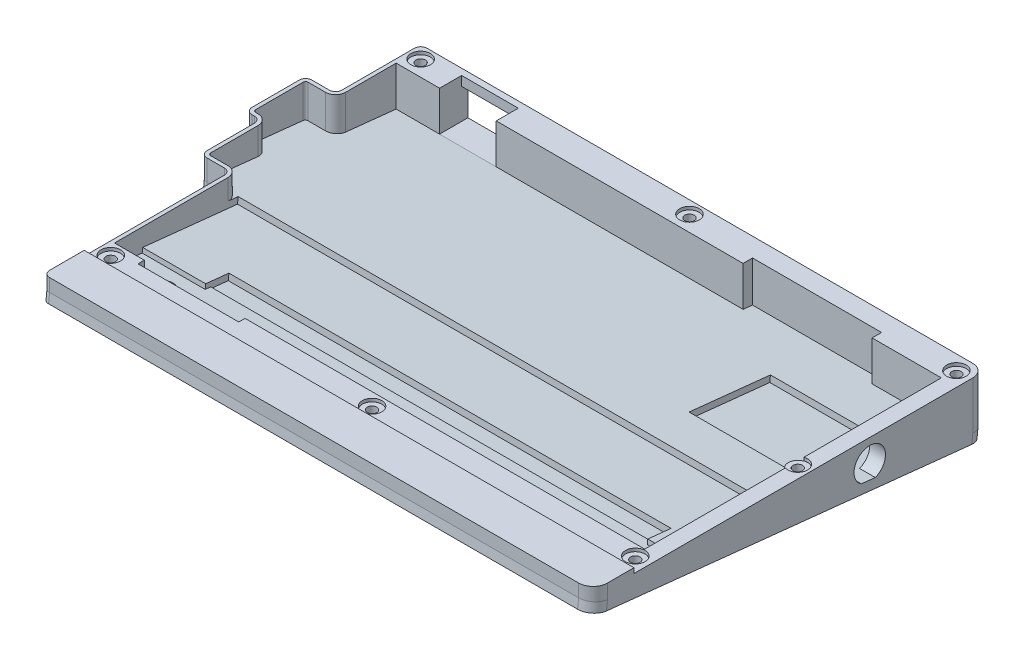
from build123d import *

# Parameters (mm, degrees)
SKETCH1_R                = 1.1
BOSS_EXTRUDE2_DEPTH      = 4.7
BOSS_EXTRUDE2_2_DEPTH    = 4.7
BODY_MOVE_COPY1_ANGLE    = 180
BOSS_EXTRUDE3_REACH      = 207.065
CUT_EXTRUDE1_DEPTH       = 171.122265517
CUT_EXTRUDE2_DEPTH       = 173.598879961
BOSS_EXTRUDE4_DEPTH      = 182.770947
BOSS_EXTRUDE10_DEPTH     = 11
CUT_EXTRUDE8_DEPTH       = 11
BOSS_EXTRUDE11_REACH     = 183.171
BOSS_EXTRUDE14_REACH     = 156.96
SKETCH47_R               = 3.1
CUT_EXTRUDE17_DEPTH      = 1.8
CUT_EXTRUDE18_DEPTH      = 0.8
CUT_EXTRUDE19_DEPTH      = 10
SKETCH50_W               = 39
SKETCH50_H               = 26
CUT_EXTRUDE20_DEPTH      = 10
SKETCH51_W               = 168.69
SKETCH51_H               = 3.9
BOSS_EXTRUDE15_DEPTH     = 13.5
SKETCH52_W               = 168.69
SKETCH52_H               = 3.9
CUT_EXTRUDE21_DEPTH      = 13.5
BOSS_EXTRUDE16_DEPTH     = 174.69
SKETCH54_W               = 2
SKETCH54_H               = 1.96610301
SKETCH54_H_2             = 3.9
BOSS_EXTRUDE17_DEPTH     = 2
SKETCH55_W               = 4
SKETCH55_H               = 3.9
SKETCH55_H_2             = 2.74608012
BOSS_EXTRUDE18_DEPTH     = 4
CUT_EXTRUDE22_DEPTH      = 13.5
CUT_EXTRUDE22_DEPTH_BACK = 13.5
CUT_EXTRUDE23_DEPTH      = 13.5
CUT_EXTRUDE23_DEPTH_BACK = 13.5
CUT_EXTRUDE24_START      = -2.9
SKETCH58_R               = 1.1
CUT_EXTRUDE24_DEPTH      = 2.9
SKETCH59_R               = 3.1
CUT_EXTRUDE25_DEPTH      = 1
SKETCH60_R               = 3.1
CUT_EXTRUDE26_DEPTH      = 1
CUT_EXTRUDE27_DEPTH      = 13.5
SKETCH62_W               = 39
SKETCH62_H               = 26
SKETCH62_W_2             = 168.490946585
SKETCH62_H_2             = 24.16499069
BOSS_EXTRUDE20_DEPTH     = 2
SKETCH63_W               = 18
SKETCH63_H               = 9
CUT_EXTRUDE28_DEPTH      = 12.646908
CUT_EXTRUDE29_DEPTH      = 14
SKETCH67_R               = 1.5
CUT_EXTRUDE30_DEPTH      = 4
SKETCH68_W               = 168.490946585
SKETCH68_H               = 15.350532898
CUT_EXTRUDE31_DEPTH      = 2
SKETCH69_W               = 168.490946585
SKETCH69_H               = 24.16499069
CUT_EXTRUDE32_DEPTH      = 20
SKETCH70_W               = 32
SKETCH70_H               = 2.011016559
CUT_EXTRUDE33_DEPTH      = 20
SKETCH72_W               = 168.490946585
SKETCH72_H               = 1.989043791
BOSS_EXTRUDE21_DEPTH     = 7.5
SKETCH74_W               = 168.490946585
SKETCH74_H               = 0.5
BOSS_EXTRUDE22_DEPTH     = 11
SKETCH76_W               = 32
SKETCH76_H               = 0.5
BOSS_EXTRUDE23_DEPTH     = 2.011016559
SKETCH81_W               = 8
SKETCH81_H               = 1.989043791
SKETCH81_W_2             = 20
BOSS_EXTRUDE24_DEPTH     = 7.45
SKETCH82_R               = 2.5
CUT_EXTRUDE34_DEPTH      = 0.5
BOSS_EXTRUDE25_DEPTH     = 1
BOSS_EXTRUDE27_DEPTH     = 1
SKETCH90_W               = 5.5
SKETCH90_H               = 5.5
CUT_EXTRUDE35_DEPTH      = 2
BOSS_EXTRUDE28_START     = -5
BOSS_EXTRUDE28_DEPTH     = 5
BOSS_EXTRUDE29_DEPTH     = 1.6
CUT_EXTRUDE36_DEPTH      = 1.6
BOSS_EXTRUDE30_REACH     = 179.446
SKETCH94_R               = 3
SKETCH94_R_2             = 1.5
SKETCH95_R               = 1.5
CUT_EXTRUDE37_DEPTH      = 4
SKETCH96_R               = 1.5
CUT_EXTRUDE38_DEPTH      = 1.3
SKETCH97_W               = 18
SKETCH97_H               = 2
BOSS_EXTRUDE31_DEPTH     = 3
BOSS_EXTRUDE32_DEPTH     = 2


with BuildPart() as part:
    # Sketch1 → Boss-Extrude2 (new body)
    with BuildSketch(Plane(origin=(0, 0, 0), x_dir=(1, 0, 0), z_dir=(0, 1, 0))):
        with BuildLine():
            Line((138.419647052, 31.751786673), (125.419647052, 31.751786673))
            Line((125.419647052, 31.751786673), (125.419647052, 22.751786673))
            Line((125.419647052, 22.751786673), (139.220593636, 22.751786673))
            Line((139.220593636, 22.751786673), (139.220593636, 6.701786673))
            ThreePointArc((139.220593636, 6.701786673), (140.157574688, 4.43971431), (142.419647052, 3.502733258))
            Line((142.419647052, 3.502733258), (147.949647052, 3.502733258))
            ThreePointArc((147.949647052, 3.502733258), (148.516001813, 3.268141435), (148.750593636, 2.701786673))
            Line((148.750593636, 2.701786673), (148.750593636, -12.348213327))
            ThreePointArc((148.750593636, -12.348213327), (148.516001813, -12.914568088), (147.949647052, -13.149159912))
            Line((147.949647052, -13.149159912), (147.189647052, -13.149159912))
            ThreePointArc((147.189647052, -13.149159912), (144.927574688, -14.086140963), (143.990593636, -16.348213327))
            Line((143.990593636, -16.348213327), (143.990593636, -31.398213327))
            ThreePointArc((143.990593636, -31.398213327), (143.756001813, -31.964568088), (143.189647052, -32.199159912))
            Line((143.189647052, -32.199159912), (137.669647052, -32.199159912))
            ThreePointArc((137.669647052, -32.199159912), (135.407574688, -33.136140963), (134.470593636, -35.398213327))
            Line((134.470593636, -35.398213327), (134.470593636, -71.498213327))
            Line((134.470593636, -71.498213327), (124.979647052, -71.498213327))
            Line((124.979647052, -71.498213327), (124.979647052, -73.498213327))
            Line((124.979647052, -73.498213327), (92.979647052, -73.498213327))
            Line((92.979647052, -73.498213327), (92.979647052, -71.498213327))
            Line((92.979647052, -71.498213327), (-34.020352948, -71.498213327))
            Line((-34.020352948, -71.498213327), (-34.020352948, -25.600264134))
            ThreePointArc((-34.020352948, -25.600264134), (-33.020352948, -23.868213327), (-34.020352948, -22.136162519))
            Line((-34.020352948, -22.136162519), (-34.020352948, -13.498213327))
            Line((-34.020352948, -13.498213327), (-39.020352948, -13.498213327))
            Line((-39.020352948, -13.498213327), (-39.020352948, -75.498213327))
            ThreePointArc((-39.020352948, -75.498213327), (-37.848780073, -78.326640452), (-35.020352948, -79.498213327))
            Line((-35.020352948, -79.498213327), (133.669647052, -79.498213327))
            ThreePointArc((133.669647052, -79.498213327), (135.083860614, -78.912426889), (135.669647052, -77.498213327))
            Line((135.669647052, -77.498213327), (135.669647052, -35.398213327))
            ThreePointArc((135.669647052, -35.398213327), (136.255433489, -33.983999764), (137.669647052, -33.398213327))
            Line((137.669647052, -33.398213327), (143.189647052, -33.398213327))
            ThreePointArc((143.189647052, -33.398213327), (144.603860614, -32.812426889), (145.189647052, -31.398213327))
            Line((145.189647052, -31.398213327), (145.189647052, -16.348213327))
            ThreePointArc((145.189647052, -16.348213327), (145.775433489, -14.933999764), (147.189647052, -14.348213327))
            Line((147.189647052, -14.348213327), (147.949647052, -14.348213327))
            ThreePointArc((147.949647052, -14.348213327), (149.363860614, -13.762426889), (149.949647052, -12.348213327))
            Line((149.949647052, -12.348213327), (149.949647052, 2.701786673))
            ThreePointArc((149.949647052, 2.701786673), (149.363860614, 4.116000236), (147.949647052, 4.701786673))
            Line((147.949647052, 4.701786673), (142.419647052, 4.701786673))
            ThreePointArc((142.419647052, 4.701786673), (141.005433489, 5.287573111), (140.419647052, 6.701786673))
            Line((140.419647052, 6.701786673), (140.419647052, 29.751786673))
            ThreePointArc((140.419647052, 29.751786673), (139.833860614, 31.166000236), (138.419647052, 31.751786673))
        make_face()
        with Locations(Location((136.439647052, 27.751786673, 0), (0, 0, 270))):
            Circle(SKETCH1_R, mode=Mode.SUBTRACT)
        with Locations(Location((-34.420352948, -74.898213327, 0), (0, 0, 270))):
            Circle(SKETCH1_R, mode=Mode.SUBTRACT)
        with Locations(Location((48.629647052, -75.498213327, 0), (0, 0, 270))):
            Circle(SKETCH1_R, mode=Mode.SUBTRACT)
        with Locations(Location((131.649647052, -75.498213327, 0), (0, 0, 270))):
            Circle(SKETCH1_R, mode=Mode.SUBTRACT)
        with Locations(Location((-35.020352948, -23.868213327, 0), (0, 0, 270))):
            Circle(SKETCH1_R, mode=Mode.SUBTRACT)
    extrude(amount=-BOSS_EXTRUDE2_DEPTH)


with BuildPart() as body_2:
    # Sketch1 → Boss-Extrude2 2 (new body)
    with BuildSketch(Plane(origin=(0, 0, 0), x_dir=(1, 0, 0), z_dir=(0, 1, 0))):
        with BuildLine():
            Line((-35.020352948, 31.751786673), (107.419647052, 31.751786673))
            Line((107.419647052, 31.751786673), (107.419647052, 22.751786673))
            Line((107.419647052, 22.751786673), (28.979647052, 22.751786673))
            Line((28.979647052, 22.751786673), (28.979647052, 25.751786673))
            Line((28.979647052, 25.751786673), (-12.020352948, 25.751786673))
            Line((-12.020352948, 25.751786673), (-12.020352948, 22.751786673))
            Line((-12.020352948, 22.751786673), (-34.020352948, 22.751786673))
            Line((-34.020352948, 22.751786673), (-34.020352948, 3.751786673))
            Line((-34.020352948, 3.751786673), (-39.020352948, 3.751786673))
            Line((-39.020352948, 3.751786673), (-39.020352948, 27.751786673))
            ThreePointArc((-39.020352948, 27.751786673), (-37.848780073, 30.580213798), (-35.020352948, 31.751786673))
        make_face()
        with Locations(Location((-34.420352948, 27.151786673, 0), (0, 0, 270))):
            Circle(SKETCH1_R, mode=Mode.SUBTRACT)
        with Locations(Location((51.009647052, 27.751786673, 0), (0, 0, 270))):
            Circle(SKETCH1_R, mode=Mode.SUBTRACT)
    extrude(amount=-BOSS_EXTRUDE2_2_DEPTH)


with BuildPart() as body_2_1:
    # Body-Move_Copy1: moved
    add(body_2.part.rotate(Axis((55.464647052, -2.35, 0), (0, 0, 1)), BODY_MOVE_COPY1_ANGLE))


with BuildPart() as part_1:
    # Body-Move_Copy1: moved
    add(part.part.rotate(Axis((55.464647052, -2.35, 0), (0, 0, 1)), BODY_MOVE_COPY1_ANGLE))

    # Boss-Extrude3: up to this face of the body (flat: up to its plane)
    boss_extrude3_end = Plane(part_1.part.faces().sort_by_distance((-39.020352948, -2.35, 4.823213327))[0])
    # Sketch3 → Boss-Extrude3 (add, up to the picked face)
    with BuildSketch(Plane(origin=(149.949647052, 0, 0), x_dir=(0, 0, -1), z_dir=(1.0, 2.1451590503929197e-12, 0)), mode=Mode.PRIVATE) as boss_extrude3_sk1:
        Polygon((-75.498213327, -4.7), (-79.498213327, -4.7), (31.751786673, -16.392846173), (31.751786673, -4.7), (-13.498213327, -4.7), align=None)
    boss_extrude3_tool1 = split(extrude(boss_extrude3_sk1.sketch, amount=-BOSS_EXTRUDE3_REACH, mode=Mode.PRIVATE), bisect_by=boss_extrude3_end, keep=Keep.BOTH, mode=Mode.PRIVATE)

    add(body_2_1.part)  # Boss-Extrude3 merges body 2
    add(boss_extrude3_tool1.solids().sort_by(Axis((149.949647, -8.597615, 5.331547), (-1.0, -2.1451590503929197e-12, 0)))[0])

    # Sketch4 → Cut-Extrude1 (cut, through all)
    with BuildSketch(Plane(origin=(0, -4.7, 0), x_dir=(1.0, 2.1451590503929197e-12, 0), z_dir=(-2.1451590503929197e-12, 1.0, 0))):
        with BuildLine():
            Line((-36.260352948, -14.348213327), (-37.020352948, -14.348213327))
            ThreePointArc((-37.020352948, -14.348213327), (-38.434566511, -13.762426889), (-39.020352948, -12.348213327))
            Line((-39.020352948, -12.348213327), (-39.020352948, -79.498213327))
            Line((-39.020352948, -79.498213327), (-22.740352948, -79.498213327))
            ThreePointArc((-22.740352948, -79.498213327), (-24.154566511, -78.912426889), (-24.740352948, -77.498213327))
            Line((-24.740352948, -77.498213327), (-24.740352948, -35.398213327))
            ThreePointArc((-24.740352948, -35.398213327), (-25.326139386, -33.983999764), (-26.740352948, -33.398213327))
            Line((-26.740352948, -33.398213327), (-32.260352948, -33.398213327))
            ThreePointArc((-32.260352948, -33.398213327), (-33.674566511, -32.812426889), (-34.260352948, -31.398213327))
            Line((-34.260352948, -31.398213327), (-34.260352948, -16.348213327))
            ThreePointArc((-34.260352948, -16.348213327), (-34.846139386, -14.933999764), (-36.260352948, -14.348213327))
        make_face()
        with BuildLine():
            Line((-29.490352948, 6.701786673), (-29.490352948, 29.751786673))
            ThreePointArc((-29.490352948, 29.751786673), (-28.904566511, 31.166000236), (-27.490352948, 31.751786673))
            Line((-27.490352948, 31.751786673), (-39.020352948, 31.751786673))
            Line((-39.020352948, 31.751786673), (-39.020352948, 2.701786673))
            ThreePointArc((-39.020352948, 2.701786673), (-38.434566511, 4.116000236), (-37.020352948, 4.701786673))
            Line((-37.020352948, 4.701786673), (-31.490352948, 4.701786673))
            ThreePointArc((-31.490352948, 4.701786673), (-30.076139386, 5.287573111), (-29.490352948, 6.701786673))
        make_face()
        with BuildLine():
            Line((145.949647052, -79.498213327), (149.949647052, -79.498213327))
            Line((149.949647052, -79.498213327), (149.949647052, -75.498213327))
            ThreePointArc((149.949647052, -75.498213327), (148.778074176, -78.326640452), (145.949647052, -79.498213327))
        make_face()
        with BuildLine():
            Line((149.949647052, 31.751786673), (145.949647052, 31.751786673))
            ThreePointArc((145.949647052, 31.751786673), (148.778074176, 30.580213798), (149.949647052, 27.751786673))
            Line((149.949647052, 27.751786673), (149.949647052, 31.751786673))
        make_face()
    extrude(amount=-CUT_EXTRUDE1_DEPTH, mode=Mode.SUBTRACT)

    # Sketch10 → Cut-Extrude2 (cut, through all)
    with BuildSketch(Plane(origin=(0, 15, 0), x_dir=(1.0, 2.1451590503929197e-12, 0), z_dir=(-2.1451590503929197e-12, 1.0, 0))):
        with BuildLine():
            ThreePointArc((144.949647052, -22.136162519), (143.949647052, -23.868213327), (144.949647052, -25.600264134))
            Line((144.949647052, -25.600264134), (144.949647052, -71.498213327))
            Line((144.949647052, -71.498213327), (17.949647052, -71.498213327))
            Line((17.949647052, -71.498213327), (17.949647052, -73.498213327))
            Line((17.949647052, -73.498213327), (-14.050352948, -73.498213327))
            Line((-14.050352948, -73.498213327), (-14.050352948, -71.498213327))
            Line((-14.050352948, -71.498213327), (-23.541299533, -71.498213327))
            Line((-23.541299533, -71.498213327), (-23.541299533, -35.398213327))
            ThreePointArc((-23.541299533, -35.398213327), (-24.478280585, -33.136140963), (-26.740352948, -32.199159912))
            Line((-26.740352948, -32.199159912), (-32.260352948, -32.199159912))
            ThreePointArc((-32.260352948, -32.199159912), (-32.82670771, -31.964568088), (-33.061299533, -31.398213327))
            Line((-33.061299533, -31.398213327), (-33.061299533, -16.348213327))
            ThreePointArc((-33.061299533, -16.348213327), (-33.998280585, -14.086140963), (-36.260352948, -13.149159912))
            Line((-36.260352948, -13.149159912), (-37.020352948, -13.149159912))
            ThreePointArc((-37.020352948, -13.149159912), (-37.58670771, -12.914568088), (-37.821299533, -12.348213327))
            Line((-37.821299533, -12.348213327), (-37.821299533, 2.701786673))
            ThreePointArc((-37.821299533, 2.701786673), (-37.58670771, 3.268141435), (-37.020352948, 3.502733258))
            Line((-37.020352948, 3.502733258), (-31.490352948, 3.502733258))
            ThreePointArc((-31.490352948, 3.502733258), (-29.228280585, 4.43971431), (-28.291299533, 6.701786673))
            Line((-28.291299533, 6.701786673), (-28.291299533, 22.751786673))
            Line((-28.291299533, 22.751786673), (-14.490352948, 22.751786673))
            Line((-14.490352948, 22.751786673), (3.509647052, 22.751786673))
            Line((3.509647052, 22.751786673), (81.949647052, 22.751786673))
            Line((81.949647052, 22.751786673), (81.949647052, 25.751786673))
            Line((81.949647052, 25.751786673), (122.949647052, 25.751786673))
            Line((122.949647052, 25.751786673), (122.949647052, 22.751786673))
            Line((122.949647052, 22.751786673), (144.949647052, 22.751786673))
            Line((144.949647052, 22.751786673), (144.949647052, 3.751786673))
            Line((144.949647052, 3.751786673), (144.949647052, -13.498213327))
            Line((144.949647052, -13.498213327), (144.949647052, -22.136162519))
        make_face()
    extrude(amount=-CUT_EXTRUDE2_DEPTH, mode=Mode.SUBTRACT)

    # Sketch11 → Boss-Extrude4 (add)
    with BuildSketch(Plane.ZY.offset(-144.949647052)):
        Polygon((-22.751786673, -15.446908056), (71.498213327, -5.540833882), (71.498213327, -3.540833882), (-22.751786673, -13.446908056), align=None)
    extrude(amount=BOSS_EXTRUDE4_DEPTH)

    # Sketch26 → Boss-Extrude10 (add)
    with BuildSketch(Plane.ZY.offset(37.821299533)):
        Polygon((-4.534403537, -11.532183933), (-22.751786673, -13.446908056), (-22.751786673, -15.446908056), (-4.534403537, -13.532183933), align=None)
        Polygon((-4.534403537, -13.532183933), (-4.534403537, -11.532183933), (14.18083019, -9.565133604), (14.18083019, -11.565133604), align=None)
        Polygon((71.498213327, -3.540833882), (14.18083019, -9.565133604), (14.18083019, -11.565133604), (71.498213327, -5.540833882), align=None)
    extrude(amount=BOSS_EXTRUDE10_DEPTH)

    # Sketch28 → Cut-Extrude8 (cut)
    with BuildSketch(Plane(origin=(0, -10.934803236, 1.149294132), x_dir=(1.0, 2.1216446839871725e-12, -2.2299384201287759e-13), z_dir=(-2.1333312960407e-12, 0.9945218953684236, -0.10452846326622464))):
        with BuildLine():
            Line((-37.020352948, 5.883310194), (-31.490352948, 5.883310194))
            add(Edge.make_bspline(
                [(-31.490352948, 5.883310194), (-29.490352948, 5.883310194), (-29.490352948, 7.894326753)],
                knots=[3.141592654, 3.141592654, 3.141592654, 4.71238898, 4.71238898, 4.71238898], degree=2, weights=[1, 0.707106781, 1]))
            Line((-29.490352948, 7.894326753), (-29.490352948, 24.03273464))
            Line((-29.490352948, 24.03273464), (-48.821299533, 24.03273464))
            Line((-48.821299533, 24.03273464), (-48.821299533, -70.736420709))
            Line((-48.821299533, -70.736420709), (-24.740352948, -70.736420709))
            Line((-24.740352948, -70.736420709), (-24.740352948, -34.437571817))
            add(Edge.make_bspline(
                [(-24.740352948, -34.437571817), (-24.740352948, -32.426555257), (-26.740352948, -32.426555257)],
                knots=[4.71238898, 4.71238898, 4.71238898, 6.283185307, 6.283185307, 6.283185307], degree=2, weights=[1, 0.707106781, 1]))
            Line((-26.740352948, -32.426555257), (-32.260352948, -32.426555257))
            add(Edge.make_bspline(
                [(-34.260352948, -30.415538698), (-34.260352948, -32.426555257), (-32.260352948, -32.426555257)],
                knots=[1.570796327, 1.570796327, 1.570796327, 3.141592654, 3.141592654, 3.141592654], degree=2, weights=[1, 0.707106781, 1]))
            Line((-34.260352948, -30.415538698), (-34.260352948, -15.282639091))
            add(Edge.make_bspline(
                [(-34.260352948, -15.282639091), (-34.260352948, -13.271622532), (-36.260352948, -13.271622532)],
                knots=[4.71238898, 4.71238898, 4.71238898, 6.283185307, 6.283185307, 6.283185307], degree=2, weights=[1, 0.707106781, 1]))
            Line((-36.260352948, -13.271622532), (-37.020352948, -13.271622532))
            add(Edge.make_bspline(
                [(-39.020352948, -11.260605973), (-39.020352948, -13.271622532), (-37.020352948, -13.271622532)],
                knots=[1.570796327, 1.570796327, 1.570796327, 3.141592654, 3.141592654, 3.141592654], degree=2, weights=[1, 0.707106781, 1]))
            Line((-39.020352948, -11.260605973), (-39.020352948, 3.872293635))
            add(Edge.make_bspline(
                [(-37.020352948, 5.883310194), (-39.020352948, 5.883310194), (-39.020352948, 3.872293635)],
                knots=[0, 0, 0, 1.570796327, 1.570796327, 1.570796327], degree=2, weights=[1, 0.707106781, 1]))
        make_face()
        Polygon((-29.490352948, 30.802104907), (-29.490352948, 24.03273464), (-48.821299533, 24.03273464), (-52.713190327, 28.392879606), align=None)
    extrude(amount=-CUT_EXTRUDE8_DEPTH, mode=Mode.SUBTRACT)

    # Sketch30 → Boss-Extrude11 (add, up to next)
    with BuildSketch(Plane.ZY.offset(-122.949647052), mode=Mode.PRIVATE) as boss_extrude11_sk1:
        Polygon((-25.751786673, -15.762220762), (-22.751786673, -15.446908056), (-22.751786673, -13.446908056), (-25.751786673, -13.762220762), align=None)
    boss_extrude11_tool1 = extrude(boss_extrude11_sk1.sketch, amount=BOSS_EXTRUDE11_REACH, mode=Mode.PRIVATE) - part_1.part
    add(boss_extrude11_tool1.solids().sort_by_distance((122.949647, -14.604564, -24.251787))[0])

    # Sketch32 → Boss-Extrude14 (add, up to next)
    with BuildSketch(Plane.ZY.offset(-17.949647052), mode=Mode.PRIVATE) as boss_extrude14_sk1:
        Polygon((73.498213327, -5.330625412), (71.498213327, -5.540833882), (71.498213327, -3.540833882), (73.498213327, -3.330625412), align=None)
    boss_extrude14_tool1 = extrude(boss_extrude14_sk1.sketch, amount=BOSS_EXTRUDE14_REACH, mode=Mode.PRIVATE) - part_1.part
    add(boss_extrude14_tool1.solids().sort_by_distance((17.949647, -4.43573, 72.498213))[0])

    # Sketch47 → Cut-Extrude17 (cut)
    with BuildSketch(Plane(origin=(0, 0, 0), x_dir=(1.0, 2.1451590503929197e-12, 0), z_dir=(-2.1451590503929197e-12, 1.0, 0))):
        with Locations(Location((145.349647052, -74.898213327, 0), (0, 0, 180))):
            Circle(SKETCH47_R)
        with Locations(Location((62.299647052, -75.498213327, 0), (0, 0, 180))):
            Circle(SKETCH47_R)
        with Locations(Location((-20.720352948, -75.498213327, 0), (0, 0, 180))):
            Circle(SKETCH47_R)
        with Locations(Location((-25.510352948, 27.751786673, 0), (0, 0, 180))):
            Circle(SKETCH47_R)
        with Locations(Location((59.919647052, 27.751786673, 0), (0, 0, 180))):
            Circle(SKETCH47_R)
        with Locations(Location((145.349647052, 27.151786673, 0), (0, 0, 180))):
            Circle(SKETCH47_R)
        with Locations((145.949647052, -23.868213327)):
            Circle(SKETCH47_R)
    extrude(amount=-CUT_EXTRUDE17_DEPTH, mode=Mode.SUBTRACT)

    # Sketch48 → Cut-Extrude18 (cut)
    with BuildSketch(Plane(origin=(0, 0, 0), x_dir=(1.0, 2.1451590503929197e-12, 0), z_dir=(-2.1451590503929197e-12, 1.0, 0))):
        with BuildLine():
            Line((145.949647052, 31.751786673), (3.509647052, 31.751786673))
            Line((3.509647052, 31.751786673), (3.509647052, 22.751786673))
            Line((3.509647052, 22.751786673), (81.949647052, 22.751786673))
            Line((81.949647052, 22.751786673), (81.949647052, 25.751786673))
            Line((81.949647052, 25.751786673), (122.949647052, 25.751786673))
            Line((122.949647052, 25.751786673), (122.949647052, 22.751786673))
            Line((122.949647052, 22.751786673), (144.949647052, 22.751786673))
            Line((144.949647052, 22.751786673), (144.949647052, 3.751786673))
            Line((144.949647052, 3.751786673), (149.949647052, 3.751786673))
            Line((149.949647052, 3.751786673), (149.949647052, 27.751786673))
            ThreePointArc((149.949647052, 27.751786673), (148.778074176, 30.580213798), (145.949647052, 31.751786673))
        make_face()
        with BuildLine():
            Line((144.949647052, -13.498213327), (144.949647052, -20.933933177))
            ThreePointArc((144.949647052, -20.933933177), (149.049647052, -23.868213327), (144.949647052, -26.802493477))
            Line((144.949647052, -26.802493477), (144.949647052, -71.498213327))
            Line((144.949647052, -71.498213327), (17.949647052, -71.498213327))
            Line((17.949647052, -71.498213327), (17.949647052, -73.498213327))
            Line((17.949647052, -73.498213327), (-14.050352948, -73.498213327))
            Line((-14.050352948, -73.498213327), (-14.050352948, -71.498213327))
            Line((-14.050352948, -71.498213327), (-23.541299533, -71.498213327))
            Line((-23.541299533, -71.498213327), (-23.541299533, -35.398213327))
            ThreePointArc((-23.541299533, -35.398213327), (-24.478280585, -33.136140963), (-26.740352948, -32.199159912))
            Line((-26.740352948, -32.199159912), (-32.260352948, -32.199159912))
            ThreePointArc((-32.260352948, -32.199159912), (-32.82670771, -31.964568088), (-33.061299533, -31.398213327))
            Line((-33.061299533, -31.398213327), (-33.061299533, -16.348213327))
            ThreePointArc((-33.061299533, -16.348213327), (-33.998280585, -14.086140963), (-36.260352948, -13.149159912))
            Line((-36.260352948, -13.149159912), (-37.020352948, -13.149159912))
            ThreePointArc((-37.020352948, -13.149159912), (-37.58670771, -12.914568088), (-37.821299533, -12.348213327))
            Line((-37.821299533, -12.348213327), (-37.821299533, 2.701786673))
            ThreePointArc((-37.821299533, 2.701786673), (-37.58670771, 3.268141435), (-37.020352948, 3.502733258))
            Line((-37.020352948, 3.502733258), (-31.490352948, 3.502733258))
            ThreePointArc((-31.490352948, 3.502733258), (-29.228280585, 4.43971431), (-28.291299533, 6.701786673))
            Line((-28.291299533, 6.701786673), (-28.291299533, 22.751786673))
            Line((-28.291299533, 22.751786673), (-14.490352948, 22.751786673))
            Line((-14.490352948, 22.751786673), (-14.490352948, 31.751786673))
            Line((-14.490352948, 31.751786673), (-27.490352948, 31.751786673))
            ThreePointArc((-27.490352948, 31.751786673), (-28.904566511, 31.166000236), (-29.490352948, 29.751786673))
            Line((-29.490352948, 29.751786673), (-29.490352948, 6.701786673))
            ThreePointArc((-29.490352948, 6.701786673), (-30.076139386, 5.287573111), (-31.490352948, 4.701786673))
            Line((-31.490352948, 4.701786673), (-37.020352948, 4.701786673))
            ThreePointArc((-37.020352948, 4.701786673), (-38.434566511, 4.116000236), (-39.020352948, 2.701786673))
            Line((-39.020352948, 2.701786673), (-39.020352948, -12.348213327))
            ThreePointArc((-39.020352948, -12.348213327), (-38.434566511, -13.762426889), (-37.020352948, -14.348213327))
            Line((-37.020352948, -14.348213327), (-36.260352948, -14.348213327))
            ThreePointArc((-36.260352948, -14.348213327), (-34.846139386, -14.933999764), (-34.260352948, -16.348213327))
            Line((-34.260352948, -16.348213327), (-34.260352948, -31.398213327))
            ThreePointArc((-34.260352948, -31.398213327), (-33.674566511, -32.812426889), (-32.260352948, -33.398213327))
            Line((-32.260352948, -33.398213327), (-26.740352948, -33.398213327))
            ThreePointArc((-26.740352948, -33.398213327), (-25.326139386, -33.983999764), (-24.740352948, -35.398213327))
            Line((-24.740352948, -35.398213327), (-24.740352948, -77.498213327))
            ThreePointArc((-24.740352948, -77.498213327), (-24.154566511, -78.912426889), (-22.740352948, -79.498213327))
            Line((-22.740352948, -79.498213327), (145.949647052, -79.498213327))
            ThreePointArc((145.949647052, -79.498213327), (148.778074176, -78.326640452), (149.949647052, -75.498213327))
            Line((149.949647052, -75.498213327), (149.949647052, -13.498213327))
            Line((149.949647052, -13.498213327), (144.949647052, -13.498213327))
        make_face()
    extrude(amount=-CUT_EXTRUDE18_DEPTH, mode=Mode.SUBTRACT)

    # Sketch49 → Cut-Extrude19 (cut)
    with BuildSketch(Plane(origin=(0, -12.912950837, 1.357205823), x_dir=(1.0, 2.121720614363585e-12, -2.2300182262009018e-13), z_dir=(2.133407644663174e-12, -0.9945218953682742, 0.10452846326764625))):
        Polygon((17.949647052, 70.736420709), (144.949647052, 70.736420709), (144.949647052, 46.571430019), (-23.541299533, 46.571430019), (-23.541299533, 70.736420709), align=None)
    extrude(amount=-CUT_EXTRUDE19_DEPTH, mode=Mode.SUBTRACT)

    # Sketch50 → Cut-Extrude20 (cut)
    with BuildSketch(Plane(origin=(0, -12.912950837, 1.357205823), x_dir=(1.0, 2.121720614363585e-12, -2.2300182262009018e-13), z_dir=(2.133407644663174e-12, -0.9945218953682742, 0.10452846326764625))):
        with Locations((125.449647052, 4.355233577)):
            Rectangle(SKETCH50_W, SKETCH50_H)
    extrude(amount=-CUT_EXTRUDE20_DEPTH, mode=Mode.SUBTRACT)

    # Sketch51 → Boss-Extrude15 (add)
    with BuildSketch(Plane.XY.offset(79.498213327)):
        with Locations((61.604647052, -2.75)):
            Rectangle(SKETCH51_W, SKETCH51_H)
    extrude(amount=BOSS_EXTRUDE15_DEPTH)

    # Sketch52 → Cut-Extrude21 (cut)
    with BuildSketch(Plane.XY.offset(92.998213327)):
        with Locations((61.604647052, -2.75)):
            Rectangle(SKETCH52_W, SKETCH52_H)
    extrude(amount=-CUT_EXTRUDE21_DEPTH, mode=Mode.SUBTRACT)

    # Sketch53 → Boss-Extrude16 (add)
    with BuildSketch(Plane(origin=(149.949647052, 0, 0), x_dir=(0, 0, -1), z_dir=(1.0, 2.1451590503929197e-12, 0))):
        Polygon((-79.498213327, -0.8), (-79.498213327, -4.7), (-92.924258914, -3.288865746), (-92.924258914, -0.8), align=None)
    extrude(amount=-BOSS_EXTRUDE16_DEPTH)

    # Sketch54 → Boss-Extrude17 (add)
    with BuildSketch(Plane(origin=(0, 0, 79.498213327), x_dir=(-1, 0, 0), z_dir=(0, 0, -1))):
        with Locations((23.740352948, -5.683051505)):
            Rectangle(SKETCH54_W, SKETCH54_H)
        with Locations((23.740352948, -2.75)):
            Rectangle(SKETCH54_W, SKETCH54_H_2)
    extrude(amount=BOSS_EXTRUDE17_DEPTH)

    # Sketch55 → Boss-Extrude18 (add)
    with BuildSketch(Plane(origin=(0, 0, 79.498213327), x_dir=(-1, 0, 0), z_dir=(0, 0, -1))):
        with Locations((-147.949647052, -2.75)):
            Rectangle(SKETCH55_W, SKETCH55_H)
        with Locations((-147.949647052, -6.07304006)):
            Rectangle(SKETCH55_W, SKETCH55_H_2)
    extrude(amount=BOSS_EXTRUDE18_DEPTH)

    # Sketch56 → Cut-Extrude22 (cut, two sides)
    with BuildSketch(Plane.ZY.offset(24.740352948)) as cut_extrude22_sk:
        Polygon((77.498213327, -4.910208471), (79.498213327, -4.7), (79.498213327, -6.66610301), (77.498213327, -6.66610301), align=None)
    extrude(amount=CUT_EXTRUDE22_DEPTH, mode=Mode.SUBTRACT)
    extrude(cut_extrude22_sk.sketch, amount=-CUT_EXTRUDE22_DEPTH_BACK, mode=Mode.SUBTRACT)

    # Sketch57 → Cut-Extrude23 (cut, two sides)
    with BuildSketch(Plane(origin=(149.949647052, 0, 0), x_dir=(0, 0, -1), z_dir=(1.0, 2.1451590503929197e-12, 0))) as cut_extrude23_sk:
        Polygon((-75.498213327, -5.120416941), (-79.498213327, -4.7), (-79.498213327, -7.44608012), (-75.498213327, -7.44608012), align=None)
    extrude(amount=CUT_EXTRUDE23_DEPTH, mode=Mode.SUBTRACT)
    extrude(cut_extrude23_sk.sketch, amount=-CUT_EXTRUDE23_DEPTH_BACK, mode=Mode.SUBTRACT)

    # Sketch58 → Cut-Extrude24 (cut)
    with BuildSketch(Plane(origin=(0, -1.8, 0), x_dir=(1.0, 2.1451590503929197e-12, 0), z_dir=(-2.1451590503929197e-12, 1.0, 0)).offset(CUT_EXTRUDE24_START)):
        with Locations(Location((145.349647052, -74.898213327, 0), (0, 0, 270))):
            Circle(SKETCH58_R)
    extrude(amount=CUT_EXTRUDE24_DEPTH, mode=Mode.SUBTRACT)

    # Sketch59 → Cut-Extrude25 (cut)
    with BuildSketch(Plane(origin=(0, -1.8, 0), x_dir=(1.0, 2.1451590503929197e-12, 0), z_dir=(-2.1451590503929197e-12, 1.0, 0))):
        with Locations(Location((145.349647052, -74.898213327, 0), (0, 0, 180))):
            Circle(SKETCH59_R)
    extrude(amount=CUT_EXTRUDE25_DEPTH, mode=Mode.SUBTRACT)

    # Sketch60 → Cut-Extrude26 (cut)
    with BuildSketch(Plane(origin=(0, -1.8, 0), x_dir=(1.0, 2.1451590503929197e-12, 0), z_dir=(-2.1451590503929197e-12, 1.0, 0))):
        with Locations(Location((-20.720352948, -75.498213327, 0), (0, 0, 180))):
            Circle(SKETCH60_R)
    extrude(amount=CUT_EXTRUDE26_DEPTH, mode=Mode.SUBTRACT)

    # Sketch61 → Cut-Extrude27 (cut)
    with BuildSketch(Plane(origin=(0, -0.8, 0), x_dir=(1.0, 2.1451590503929197e-12, 0), z_dir=(-2.1451590503929197e-12, 1.0, 0))):
        with BuildLine():
            Line((-24.740352948, -90.924258914), (-24.740352948, -92.924258914))
            Line((-24.740352948, -92.924258914), (-22.740352948, -92.924258914))
            ThreePointArc((-22.740352948, -92.924258914), (-24.154566511, -92.338472477), (-24.740352948, -90.924258914))
        make_face()
        with BuildLine():
            ThreePointArc((149.949647052, -88.324258914), (148.602338245, -91.576950108), (145.349647052, -92.924258914))
            Line((145.349647052, -92.924258914), (149.949647052, -92.924258914))
            Line((149.949647052, -92.924258914), (149.949647052, -88.324258914))
        make_face()
    extrude(amount=-CUT_EXTRUDE27_DEPTH, mode=Mode.SUBTRACT)

    # Sketch62 → Boss-Extrude20 (add)
    with BuildSketch(Plane(origin=(0, -12.912950837, 1.357205823), x_dir=(1.0, 2.121720614363585e-12, -2.2300182262009018e-13), z_dir=(2.133407644663174e-12, -0.9945218953682742, 0.10452846326764625))):
        with BuildLine():
            Line((-12.490352948, -33.291366083), (132.949647052, -33.291366083))
            Line((132.949647052, -33.291366083), (132.949647052, -18.291366083))
            Line((132.949647052, -18.291366083), (149.949647052, -18.291366083))
            Line((149.949647052, -18.291366083), (149.949647052, 77.071430019))
            Line((149.949647052, 77.071430019), (132.949647052, 77.071430019))
            Line((132.949647052, 77.071430019), (132.949647052, 92.071430019))
            Line((132.949647052, 92.071430019), (-7.740352948, 92.071430019))
            Line((-7.740352948, 92.071430019), (-7.740352948, 77.071430019))
            Line((-7.740352948, 77.071430019), (-24.740352948, 77.071430019))
            Line((-24.740352948, 77.071430019), (-24.740352948, 34.437571817))
            add(Edge.make_bspline(
                [(-26.740352948, 32.426555257), (-24.740352948, 32.426555257), (-24.740352948, 34.437571817)],
                knots=[0, 0, 0, 1.570796327, 1.570796327, 1.570796327], degree=2, weights=[1, 0.707106781, 1]))
            Line((-26.740352948, 32.426555257), (-32.260352948, 32.426555257))
            add(Edge.make_bspline(
                [(-32.260352948, 32.426555257), (-34.260352948, 32.426555257), (-34.260352948, 30.415538698)],
                knots=[3.141592654, 3.141592654, 3.141592654, 4.71238898, 4.71238898, 4.71238898], degree=2, weights=[1, 0.707106781, 1]))
            Line((-34.260352948, 30.415538698), (-34.260352948, 15.282639091))
            add(Edge.make_bspline(
                [(-36.260352948, 13.271622532), (-34.260352948, 13.271622532), (-34.260352948, 15.282639091)],
                knots=[0, 0, 0, 1.570796327, 1.570796327, 1.570796327], degree=2, weights=[1, 0.707106781, 1]))
            Line((-36.260352948, 13.271622532), (-37.020352948, 13.271622532))
            add(Edge.make_bspline(
                [(-37.020352948, 13.271622532), (-39.020352948, 13.271622532), (-39.020352948, 11.260605973)],
                knots=[3.141592654, 3.141592654, 3.141592654, 4.71238898, 4.71238898, 4.71238898], degree=2, weights=[1, 0.707106781, 1]))
            Line((-39.020352948, 11.260605973), (-39.020352948, -3.872293635))
            add(Edge.make_bspline(
                [(-39.020352948, -3.872293635), (-39.020352948, -5.883310194), (-37.020352948, -5.883310194)],
                knots=[4.71238898, 4.71238898, 4.71238898, 6.283185307, 6.283185307, 6.283185307], degree=2, weights=[1, 0.707106781, 1]))
            Line((-37.020352948, -5.883310194), (-31.490352948, -5.883310194))
            add(Edge.make_bspline(
                [(-29.490352948, -7.894326753), (-29.490352948, -5.883310194), (-31.490352948, -5.883310194)],
                knots=[1.570796327, 1.570796327, 1.570796327, 3.141592654, 3.141592654, 3.141592654], degree=2, weights=[1, 0.707106781, 1]))
            Line((-29.490352948, -7.894326753), (-29.490352948, -18.291366083))
            Line((-29.490352948, -18.291366083), (-12.490352948, -18.291366083))
            Line((-12.490352948, -18.291366083), (-12.490352948, -33.291366083))
        make_face()
        with Locations((125.449647052, 4.355233577)):
            Rectangle(SKETCH62_W, SKETCH62_H, mode=Mode.SUBTRACT)
        with Locations((60.70417376, 58.653925364)):
            Rectangle(SKETCH62_W_2, SKETCH62_H_2, mode=Mode.SUBTRACT)
        with Locations((125.449647052, 4.355233577)):
            Rectangle(SKETCH62_W, SKETCH62_H)
        with Locations((60.70417376, 58.653925364)):
            Rectangle(SKETCH62_W_2, SKETCH62_H_2)
    extrude(amount=BOSS_EXTRUDE20_DEPTH)

    # Sketch63 → Cut-Extrude28 (cut)
    with BuildSketch(Plane(origin=(0, -0.8, 0), x_dir=(1.0, 2.1451590503929197e-12, 0), z_dir=(-2.1451590503929197e-12, 1.0, 0))):
        with Locations((-5.490352948, 27.251786673)):
            Rectangle(SKETCH63_W, SKETCH63_H)
    extrude(amount=-CUT_EXTRUDE28_DEPTH, mode=Mode.SUBTRACT)

    # Sketch66 → Cut-Extrude29 (cut)
    with BuildSketch(Plane.ZY.offset(-144.949647052)):
        Polygon((-3.751786673, -4.7), (-3.751786673, -13.449927586), (13.498213327, -11.636879528), (13.498213327, -4.7), align=None)
    extrude(amount=-CUT_EXTRUDE29_DEPTH, mode=Mode.SUBTRACT)

    # Sketch67 → Cut-Extrude30 (cut)
    with BuildSketch(Plane(origin=(0, -1.8, 0), x_dir=(1.0, 2.1451590503929197e-12, 0), z_dir=(-2.1451590503929197e-12, 1.0, 0))):
        with Locations(Location((-25.510352948, 27.751786673, 0), (0, 0, 180))):
            Circle(SKETCH67_R)
        with Locations(Location((59.919647052, 27.751786673, 0), (0, 0, 180))):
            Circle(SKETCH67_R)
        with Locations(Location((145.349647052, 27.151786673, 0), (0, 0, 180))):
            Circle(SKETCH67_R)
        with Locations(Location((145.949647052, -23.868213327, 0), (0, 0, 180))):
            Circle(SKETCH67_R)
        with Locations(Location((145.349647052, -74.898213327, 0), (0, 0, 180))):
            Circle(SKETCH67_R)
        with Locations(Location((62.299647052, -75.498213327, 0), (0, 0, 180))):
            Circle(SKETCH67_R)
        with Locations(Location((-20.720352948, -75.498213327, 0), (0, 0, 180))):
            Circle(SKETCH67_R)
    extrude(amount=-CUT_EXTRUDE30_DEPTH, mode=Mode.SUBTRACT)

    # Sketch68 → Cut-Extrude31 (cut)
    with BuildSketch(Plane(origin=(0, -10.934803236, 1.149294132), x_dir=(1.0, 2.1216446839871725e-12, -2.2299384201287759e-13), z_dir=(-2.1333312960407e-12, 0.9945218953684236, -0.10452846326622464))):
        with Locations((60.70417376, -38.89616357)):
            Rectangle(SKETCH68_W, SKETCH68_H)
    extrude(amount=-CUT_EXTRUDE31_DEPTH, mode=Mode.SUBTRACT)

    # Sketch69 → Cut-Extrude32 (cut)
    with BuildSketch(Plane(origin=(0, -12.912950837, 1.357205823), x_dir=(1.0, 2.121710649813735e-12, -2.230007753036985e-13), z_dir=(-2.1333976252257977e-12, 0.9945218953682742, -0.10452846326764627))):
        with Locations((60.70417376, -58.653925364)):
            Rectangle(SKETCH69_W, SKETCH69_H)
    extrude(amount=-CUT_EXTRUDE32_DEPTH, mode=Mode.SUBTRACT)

    # Sketch70 → Cut-Extrude33 (cut)
    with BuildSketch(Plane(origin=(0, -10.934803236, 1.149294132), x_dir=(1.0, 2.1216446839871725e-12, -2.2299384201287759e-13), z_dir=(-2.1333312960407e-12, 0.9945218953684236, -0.10452846326622464))):
        with Locations((1.949647052, -71.741928989)):
            Rectangle(SKETCH70_W, SKETCH70_H)
    extrude(amount=-CUT_EXTRUDE33_DEPTH, mode=Mode.SUBTRACT)

    # Sketch72 → Boss-Extrude21 (add)
    with BuildSketch(Plane(origin=(0, 4.868040012, 46.316306852), x_dir=(1, 0, 0), z_dir=(1.6485054276844242e-14, 0.1045284632676463, 0.9945218953682742))):
        with Locations((60.70417376, -13.989557085)):
            Rectangle(SKETCH72_W, SKETCH72_H)
    extrude(amount=BOSS_EXTRUDE21_DEPTH)

    # Sketch74 → Boss-Extrude22 (add)
    with BuildSketch(Plane(origin=(0, 7.393969354, 70.348919195), x_dir=(-1, 0, 0), z_dir=(2.247811227617879e-13, -0.10452846326764624, -0.9945218953682742))):
        with Locations((-60.70417376, -14.73407898)):
            Rectangle(SKETCH74_W, SKETCH74_H)
    extrude(amount=BOSS_EXTRUDE22_DEPTH)

    # Sketch76 → Boss-Extrude23 (add)
    with BuildSketch(Plane(origin=(0, 7.393969354, 70.348919195), x_dir=(1, 0, 0), z_dir=(-2.247260703540561e-13, 0.10452846326763915, 0.9945218953682748))):
        with Locations((1.949647052, -14.73407898)):
            Rectangle(SKETCH76_W, SKETCH76_H)
    extrude(amount=BOSS_EXTRUDE23_DEPTH)

    # Sketch81 → Boss-Extrude24 (add)
    with BuildSketch(Plane(origin=(0, 5.652003487, 53.775221068), x_dir=(1, 0, 0), z_dir=(1.649631302448038e-14, 0.10452846326764503, 0.9945218953682743))):
        with Locations((140.949647052, -13.989557085)):
            Rectangle(SKETCH81_W, SKETCH81_H)
        with Locations((-13.541299533, -13.989557085)):
            Rectangle(SKETCH81_W_2, SKETCH81_H)
    extrude(amount=BOSS_EXTRUDE24_DEPTH)

    # Sketch82 → Cut-Extrude34 (cut)
    with BuildSketch(Plane(origin=(0, -14.404733679, 1.513998518), x_dir=(1, 0, 0), z_dir=(0, 0.9945218953682742, -0.10452846326764625))):
        with Locations(Location((13.449647052, -67.747437268, 0), (0, 0, 270))):
            Circle(SKETCH82_R)
        with Locations(Location((-10.050352948, -67.747437268, 0), (0, 0, 270))):
            Circle(SKETCH82_R)
    extrude(amount=-CUT_EXTRUDE34_DEPTH, mode=Mode.SUBTRACT)

    # Sketch86 → Boss-Extrude25 (add)
    with BuildSketch(Plane(origin=(0, -14.901994627, 1.566262749), x_dir=(1.0, 2.121710649813735e-12, -2.230007753036985e-13), z_dir=(2.1333976252257977e-12, -0.9945218953682742, 0.10452846326764627))):
        with BuildLine():
            Line((149.949647052, 77.071430019), (132.949647052, 77.071430019))
            Line((132.949647052, 77.071430019), (132.949647052, 92.071430019))
            Line((132.949647052, 92.071430019), (-7.740352948, 92.071430019))
            Line((-7.740352948, 92.071430019), (-7.740352948, 77.071430019))
            Line((-7.740352948, 77.071430019), (-24.740352948, 77.071430019))
            Line((-24.740352948, 77.071430019), (-24.740352948, 34.437571817))
            add(Edge.make_bspline(
                [(-26.740352948, 32.426555257), (-24.740352948, 32.426555258), (-24.740352948, 34.437571817)],
                knots=[0, 0, 0, 1.570796327, 1.570796327, 1.570796327], degree=2, weights=[1, 0.707106781, 1]))
            Line((-26.740352948, 32.426555257), (-32.260352948, 32.426555257))
            add(Edge.make_bspline(
                [(-32.260352948, 32.426555257), (-34.260352948, 32.426555257), (-34.260352948, 30.415538698)],
                knots=[3.141592654, 3.141592654, 3.141592654, 4.71238898, 4.71238898, 4.71238898], degree=2, weights=[1, 0.707106781, 1]))
            Line((-34.260352948, 30.415538698), (-34.260352948, 15.282639091))
            add(Edge.make_bspline(
                [(-36.260352948, 13.271622532), (-34.260352948, 13.271622532), (-34.260352948, 15.282639091)],
                knots=[3.141592654, 3.141592654, 3.141592654, 4.71238898, 4.71238898, 4.71238898], degree=2, weights=[1, 0.707106781, 1]))
            Line((-36.260352948, 13.271622532), (-37.020352948, 13.271622532))
            add(Edge.make_bspline(
                [(-37.020352948, 13.271622532), (-39.020352948, 13.271622532), (-39.020352948, 11.260605973)],
                knots=[3.141592654, 3.141592654, 3.141592654, 4.71238898, 4.71238898, 4.71238898], degree=2, weights=[1, 0.707106781, 1]))
            Line((-39.020352948, 11.260605973), (-39.020352948, -3.872293635))
            add(Edge.make_bspline(
                [(-39.020352948, -3.872293635), (-39.020352948, -5.883310194), (-37.020352949, -5.883310194)],
                knots=[4.71238898, 4.71238898, 4.71238898, 6.283185307, 6.283185307, 6.283185307], degree=2, weights=[1, 0.707106781, 1]))
            Line((-37.020352949, -5.883310194), (-31.490352948, -5.883310194))
            add(Edge.make_bspline(
                [(-29.490352948, -7.894326753), (-29.490352948, -5.883310194), (-31.490352948, -5.883310194)],
                knots=[1.570796327, 1.570796327, 1.570796327, 3.141592654, 3.141592654, 3.141592654], degree=2, weights=[1, 0.707106781, 1]))
            Line((-29.490352948, -7.894326753), (-29.490352948, -18.291366083))
            Line((-29.490352948, -18.291366083), (-12.490352948, -18.291366083))
            Line((-12.490352948, -18.291366083), (-12.490352948, -33.291366083))
            Line((-12.490352948, -33.291366083), (132.949647052, -33.291366083))
            Line((132.949647052, -33.291366083), (132.949647052, -18.291366083))
            Line((132.949647052, -18.291366083), (149.949647052, -18.291366083))
            Line((149.949647052, -18.291366083), (149.949647052, 77.071430019))
        make_face()
    extrude(amount=BOSS_EXTRUDE25_DEPTH)

    # Sketch87 → Boss-Extrude27 (add)
    with BuildSketch(Plane(origin=(0, -12.912950837, 1.357205823), x_dir=(1.0, 2.121720614363585e-12, -2.2300182262009018e-13), z_dir=(2.133407644663174e-12, -0.9945218953682742, 0.10452846326764625))):
        with BuildLine():
            Line((132.949647052, 77.071430019), (149.949647052, 77.071430019))
            Line((149.949647052, 77.071430019), (149.949647052, 87.446091933))
            add(Edge.make_bspline(
                [(149.949647052, 87.446091933), (149.949647052, 92.071430019), (145.349647052, 92.071430019)],
                knots=[4.71238898, 4.71238898, 4.71238898, 6.283185307, 6.283185307, 6.283185307], degree=2, weights=[1, 0.707106781, 1]))
            Line((145.349647052, 92.071430019), (132.949647052, 92.071430019))
            Line((132.949647052, 92.071430019), (132.949647052, 77.071430019))
        make_face()
        with BuildLine():
            Line((-24.740352948, 77.071430019), (-7.740352948, 77.071430019))
            Line((-7.740352948, 77.071430019), (-7.740352948, 92.071430019))
            Line((-7.740352948, 92.071430019), (-22.740352948, 92.071430019))
            add(Edge.make_bspline(
                [(-22.740352948, 92.071430019), (-24.740352948, 92.071430019), (-24.740352948, 90.06041346)],
                knots=[0, 0, 0, 1.570796327, 1.570796327, 1.570796327], degree=2, weights=[1, 0.707106781, 1]))
            Line((-24.740352948, 90.06041346), (-24.740352948, 77.071430019))
        make_face()
        with BuildLine():
            Line((-12.490352948, -18.291366083), (-29.490352948, -18.291366083))
            Line((-29.490352948, -18.291366083), (-29.490352948, -31.280349524))
            add(Edge.make_bspline(
                [(-29.490352948, -31.280349524), (-29.490352948, -33.291366083), (-27.490352948, -33.291366083)],
                knots=[1.570796327, 1.570796327, 1.570796327, 3.141592654, 3.141592654, 3.141592654], degree=2, weights=[1, 0.707106781, 1]))
            Line((-27.490352948, -33.291366083), (-12.490352948, -33.291366083))
            Line((-12.490352948, -33.291366083), (-12.490352948, -18.291366083))
        make_face()
        with BuildLine():
            Line((149.949647052, -18.291366083), (132.949647052, -18.291366083))
            Line((132.949647052, -18.291366083), (132.949647052, -33.291366083))
            Line((132.949647052, -33.291366083), (145.949647052, -33.291366083))
            add(Edge.make_bspline(
                [(145.949647052, -33.291366083), (149.949647052, -33.291366083), (149.949647052, -29.269332964)],
                knots=[3.141592654, 3.141592654, 3.141592654, 4.71238898, 4.71238898, 4.71238898], degree=2, weights=[1, 0.707106781, 1]))
            Line((149.949647052, -29.269332964), (149.949647052, -18.291366083))
        make_face()
    extrude(amount=BOSS_EXTRUDE27_DEPTH)

    # Sketch90 → Cut-Extrude35 (cut)
    with BuildSketch(Plane(origin=(0, -15.896516523, 1.670791213), x_dir=(1.0, 2.1217106498137356e-12, -2.2300077530369855e-13), z_dir=(2.133397625225798e-12, -0.9945218953682742, 0.10452846326764628))):
        Polygon((146.380814721, 34.890031968), (146.380814721, 29.390031968), (146.380814721, 23.890031968), (135.380814721, 23.890031968), (135.380814721, 34.890031968), align=None)
        Polygon((62.604647052, 77.071430019), (68.104647052, 77.071430019), (68.104647052, 88.071430019), (57.104647052, 88.071430019), (57.104647052, 77.071430019), align=None)
        Polygon((60.229647052, 29.388633917), (60.229647052, 23.888633917), (65.729647052, 23.888633917), (65.729647052, 34.888633917), (54.729647052, 34.888633917), (54.729647052, 29.388633917), align=None)
        with Locations((57.479647052, 26.638633917)):
            Rectangle(SKETCH90_W, SKETCH90_H)
        Polygon((60.229647052, -18.291366083), (54.729647052, -18.291366083), (54.729647052, -29.291366083), (65.729647052, -29.291366083), (65.729647052, -18.291366083), align=None)
        Polygon((-34.571334997, -1.951366083), (-27.449015385, -1.951366083), (-23.571334997, -1.951366083), (-23.571334997, 9.048633917), (-34.571334997, 9.048633917), align=None)
    extrude(amount=-CUT_EXTRUDE35_DEPTH, mode=Mode.SUBTRACT)

    # Sketch91 → Boss-Extrude28 (add)
    with BuildSketch(Plane(origin=(149.949647052, 0, 0), x_dir=(0, 0, -1), z_dir=(1.0, 2.1451590503929197e-12, 0)).offset(BOSS_EXTRUDE28_START)):
        with BuildLine():
            Line((-13.498213327, -0.8), (-13.498213327, -11.636879528))
            Line((-13.498213327, -11.636879528), (-7.683431735, -12.2480377))
            ThreePointArc((-7.683431735, -12.2480377), (-4.47557101, -3.057656051), (-3.248597527, -12.714157558))
            Line((-3.248597527, -12.714157558), (3.751786673, -13.449927586))
            Line((3.751786673, -13.449927586), (3.751786673, -0.8))
            Line((3.751786673, -0.8), (-13.498213327, -0.8))
        make_face()
    extrude(amount=BOSS_EXTRUDE28_DEPTH)

    # Sketch92 → Boss-Extrude29 (add)
    with BuildSketch(Plane(origin=(0, -0.8, 0), x_dir=(1.0, 2.1451590503929197e-12, 0), z_dir=(-2.1451590503929197e-12, 1.0, 0))):
        with BuildLine():
            Line((-22.740352948, -92.924258914), (20.648932366, -92.924258914))
            Line((20.648932366, -92.924258914), (20.648932366, -79.924258914))
            Line((20.648932366, -79.924258914), (-22.740352948, -79.924258914))
            Line((-22.740352948, -79.924258914), (-24.740352948, -79.924258914))
            Line((-24.740352948, -79.924258914), (-24.740352948, -90.924258914))
            ThreePointArc((-24.740352948, -90.924258914), (-24.154566511, -92.338472477), (-22.740352948, -92.924258914))
        make_face()
        with BuildLine():
            Line((20.648932366, -79.924258914), (20.648932366, -92.924258914))
            Line((20.648932366, -92.924258914), (145.349647052, -92.924258914))
            ThreePointArc((145.349647052, -92.924258914), (148.602338245, -91.576950108), (149.949647052, -88.324258914))
            Line((149.949647052, -88.324258914), (149.949647052, -79.924258914))
            Line((149.949647052, -79.924258914), (145.949647052, -79.924258914))
            Line((145.949647052, -79.924258914), (20.648932366, -79.924258914))
        make_face()
        with BuildLine():
            Line((-24.740352948, -79.924258914), (-22.740352948, -79.924258914))
            ThreePointArc((-22.740352948, -79.924258914), (-24.154566511, -79.338472477), (-24.740352948, -77.924258914))
            Line((-24.740352948, -77.924258914), (-24.740352948, -79.924258914))
        make_face()
        with BuildLine():
            ThreePointArc((149.949647052, -75.924258914), (148.778074176, -78.752686039), (145.949647052, -79.924258914))
            Line((145.949647052, -79.924258914), (149.949647052, -79.924258914))
            Line((149.949647052, -79.924258914), (149.949647052, -75.924258914))
        make_face()
    extrude(amount=BOSS_EXTRUDE29_DEPTH)

    # Sketch93 → Cut-Extrude36 (cut)
    with BuildSketch(Plane(origin=(0, 0.8, 0), x_dir=(1.0, 2.1451593003984193e-12, 0), z_dir=(-2.1451593003984193e-12, 1.0, 0))):
        Polygon((-24.750281114, -77.83685923), (-22.740352948, -79.924258914), (-24.740352948, -79.924258914), align=None)
        Polygon((149.949647052, -75.924258914), (149.949647052, -79.924258914), (145.949647052, -79.924258914), align=None)
    extrude(amount=-CUT_EXTRUDE36_DEPTH, mode=Mode.SUBTRACT)

    # Boss-Extrude30: up to this plane
    boss_extrude30_end = Plane(origin=(-132.820336908, -3.540833883, 71.498213327), z_dir=(2.1333312960406997e-12, -0.9945218953684236, 0.1045284632662246))
    # Sketch94 → Boss-Extrude30 (add, up to the surface)
    with BuildSketch(Plane(origin=(0, -1.8, 0), x_dir=(1.0, 2.1451590503929197e-12, 0), z_dir=(-2.1451590503929197e-12, 1.0, 0)), mode=Mode.PRIVATE) as boss_extrude30_sk1:
        with Locations((145.949647052, -23.868213327)):
            Circle(SKETCH94_R)
        with Locations(Location((145.949647052, -23.868213327, 0), (0, 0, 180))):
            Circle(SKETCH94_R_2, mode=Mode.SUBTRACT)
    boss_extrude30_tool1 = split(extrude(boss_extrude30_sk1.sketch, amount=-BOSS_EXTRUDE30_REACH, mode=Mode.PRIVATE), bisect_by=boss_extrude30_end, keep=Keep.BOTH, mode=Mode.PRIVATE)
    add(boss_extrude30_tool1.solids().sort_by_distance((143.0345, -1.8, 23.868213))[0])

    # Sketch95 → Cut-Extrude37 (cut)
    with BuildSketch(Plane(origin=(0, -5.8, 0), x_dir=(1.0, 2.1451590503929197e-12, 0), z_dir=(-2.1451590503929197e-12, 1.0, 0))):
        with Locations(Location((-25.510352948, 27.751786673, 0), (0, 0, 180))):
            Circle(SKETCH95_R)
        with Locations(Location((59.919647052, 27.751786673, 0), (0, 0, 180))):
            Circle(SKETCH95_R)
        with Locations(Location((145.349647052, 27.151786673, 0), (0, 0, 180))):
            Circle(SKETCH95_R)
    extrude(amount=-CUT_EXTRUDE37_DEPTH, mode=Mode.SUBTRACT)

    # Sketch96 → Cut-Extrude38 (cut)
    with BuildSketch(Plane(origin=(0, -5.8, 0), x_dir=(1.0, 2.1451590503929197e-12, 0), z_dir=(-2.1451590503929197e-12, 1.0, 0))):
        with Locations(Location((-20.720352948, -75.498213327, 0), (0, 0, 180))):
            Circle(SKETCH96_R)
        with Locations(Location((62.299647052, -75.498213327, 0), (0, 0, 180))):
            Circle(SKETCH96_R)
        with Locations(Location((145.349647052, -74.898213327, 0), (0, 0, 180))):
            Circle(SKETCH96_R)
    extrude(amount=-CUT_EXTRUDE38_DEPTH, mode=Mode.SUBTRACT)

    # Sketch97 → Boss-Extrude31 (add)
    with BuildSketch(Plane(origin=(0, -0.8, 0), x_dir=(1.0, 2.1451590503929197e-12, 0), z_dir=(-2.1451590503929197e-12, 1.0, 0))):
        with Locations((-5.490352948, 30.751786673)):
            Rectangle(SKETCH97_W, SKETCH97_H)
    extrude(amount=-BOSS_EXTRUDE31_DEPTH)

    # Sketch98 → Boss-Extrude32 (add)
    with BuildSketch(Plane(origin=(0, -13.907472732, 1.461734286), x_dir=(1.0, 2.1217206143635853e-12, -2.2300182262009026e-13), z_dir=(2.1334076446631742e-12, -0.9945218953682742, 0.10452846326764627))):
        with BuildLine():
            Line((-27.490352948, -33.291366083), (-12.490352948, -33.291366083))
            Line((-12.490352948, -33.291366083), (-12.490352948, -30.291366083))
            Line((-12.490352948, -30.291366083), (-24.490352948, -30.291366083))
            Line((-24.490352948, -30.291366083), (-24.490352948, -18.291366083))
            Line((-24.490352948, -18.291366083), (-29.490352948, -18.291366083))
            Line((-29.490352948, -18.291366083), (-29.490352948, -31.280349524))
            add(Edge.make_bspline(
                [(-29.490352948, -31.280349524), (-29.490352948, -33.291366083), (-27.490352948, -33.291366083)],
                knots=[1.570796327, 1.570796327, 1.570796327, 3.141592654, 3.141592654, 3.141592654], degree=2, weights=[1, 0.707106781, 1]))
        make_face()
        with BuildLine():
            add(Edge.make_bspline(
                [(145.949647052, -33.291366083), (149.949647052, -33.291366083), (149.949647052, -29.269332964)],
                knots=[3.141592654, 3.141592654, 3.141592654, 4.71238898, 4.71238898, 4.71238898], degree=2, weights=[1, 0.707106781, 1]))
            Line((149.949647052, -29.269332964), (149.949647052, -18.291366083))
            Line((149.949647052, -18.291366083), (144.949647052, -18.291366083))
            Line((144.949647052, -18.291366083), (144.949647052, -30.291366083))
            Line((144.949647052, -30.291366083), (132.949647052, -30.291366083))
            Line((132.949647052, -30.291366083), (132.949647052, -33.291366083))
            Line((132.949647052, -33.291366083), (145.949647052, -33.291366083))
        make_face()
        with BuildLine():
            Line((132.949647052, 92.071430019), (132.949647052, 89.071430019))
            Line((132.949647052, 89.071430019), (144.949647052, 89.071430019))
            Line((144.949647052, 89.071430019), (144.949647052, 77.071430019))
            Line((144.949647052, 77.071430019), (149.949647052, 77.071430019))
            Line((149.949647052, 77.071430019), (149.949647052, 87.446091933))
            add(Edge.make_bspline(
                [(149.949647052, 87.446091933), (149.949647052, 92.071430019), (145.349647052, 92.071430019)],
                knots=[4.71238898, 4.71238898, 4.71238898, 6.283185307, 6.283185307, 6.283185307], degree=2, weights=[1, 0.707106781, 1]))
            Line((145.349647052, 92.071430019), (132.949647052, 92.071430019))
        make_face()
        with BuildLine():
            Line((-19.740352948, 89.071430019), (-7.740352948, 89.071430019))
            Line((-7.740352948, 89.071430019), (-7.740352948, 92.071430019))
            Line((-7.740352948, 92.071430019), (-22.740352948, 92.071430019))
            add(Edge.make_bspline(
                [(-22.740352948, 92.071430019), (-24.740352948, 92.071430019), (-24.740352948, 90.06041346)],
                knots=[0, 0, 0, 1.570796327, 1.570796327, 1.570796327], degree=2, weights=[1, 0.707106781, 1]))
            Line((-24.740352948, 90.06041346), (-24.740352948, 77.071430019))
            Line((-24.740352948, 77.071430019), (-19.740352948, 77.071430019))
            Line((-19.740352948, 77.071430019), (-19.740352948, 89.071430019))
        make_face()
    extrude(amount=BOSS_EXTRUDE32_DEPTH)


solid = part_1.part
